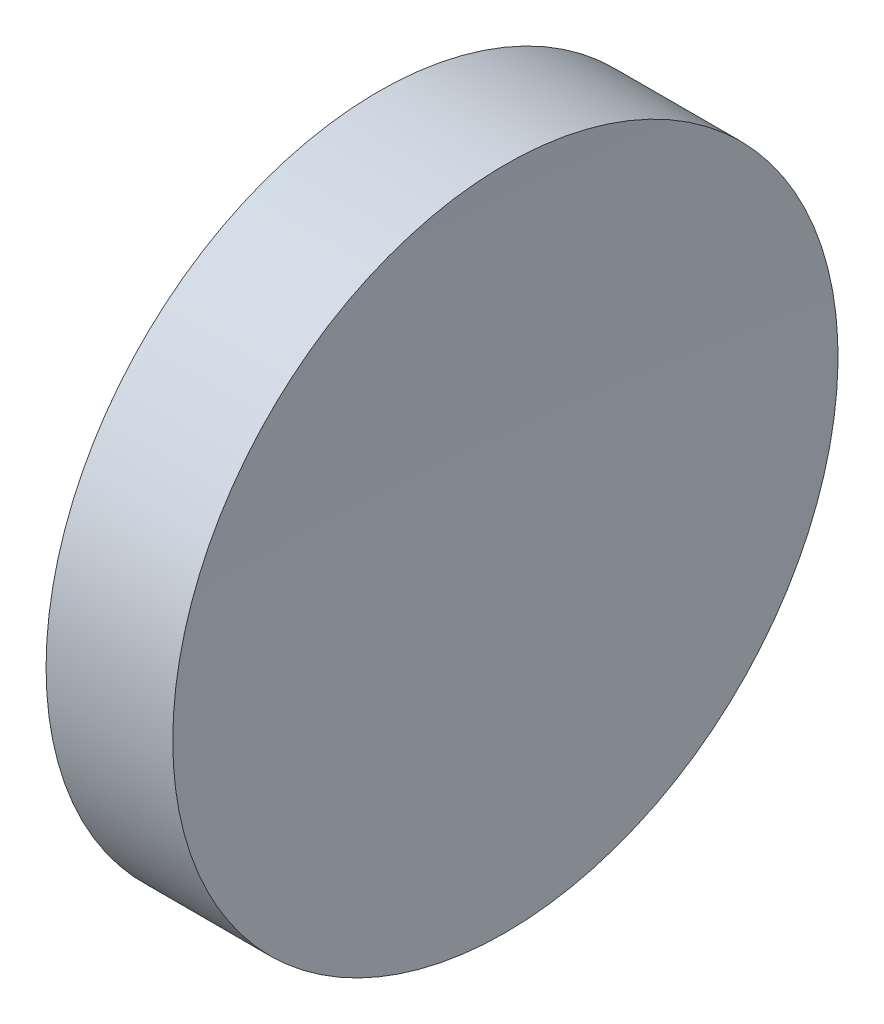
from build123d import *


with BuildPart() as part:
    # 草图1 → 旋转1 (revolve)
    with BuildSketch(Plane.XY, mode=Mode.PRIVATE) as revolve_1_sk:
        with BuildLine():
            Line((230.18531107, 138.756042247), (230.18531107, 163.756042247))
            Line((230.18531107, 163.756042247), (239.706370881, 163.756042247))
            ThreePointArc((239.706370881, 163.756042247), (239.315590335, 151.258756983), (239.185311295, 138.756042247))
            Line((239.185311295, 138.756042247), (230.18531107, 138.756042247))
        make_face()
    revolve(revolve_1_sk.sketch.rotate(Axis((217.970286004, 138.756042247, 0), (1, 0, 0)), 180), axis=Axis((217.970286004, 138.756042247, 0), (1, 0, 0)))  # turned: the seam where the file's is


solid = part.part
